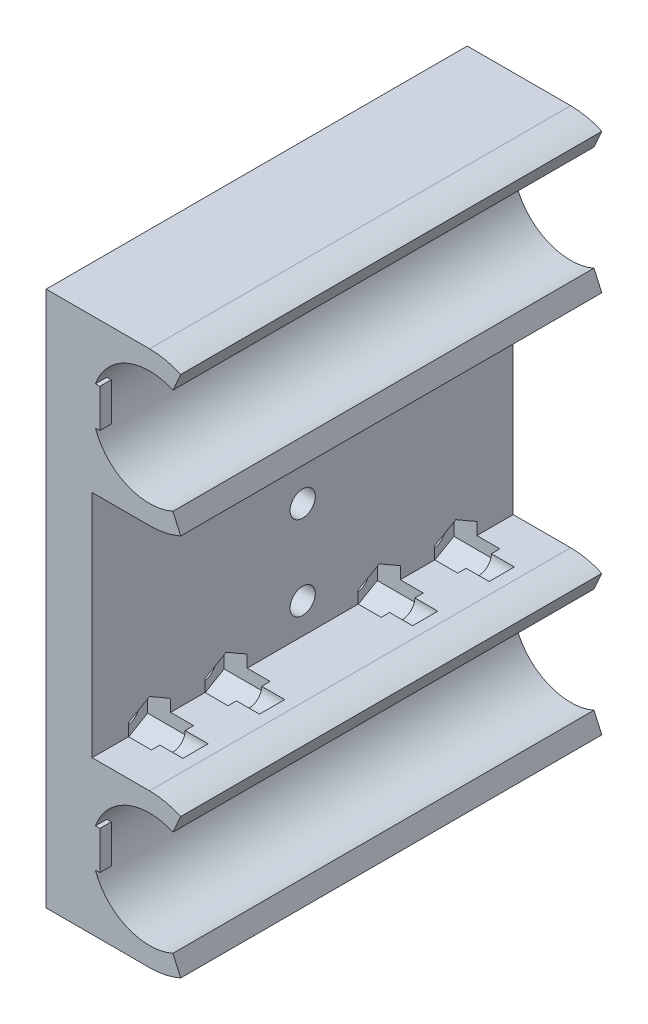
from build123d import *

# Parameters (mm, degrees)
RESSALTO_EXTRUS_O1_DEPTH   = 27.5
CORTE_EXTRUS_O3_DEPTH      = 6
CORTE_EXTRUS_O3_DEPTH_BACK = 10
ESBO_O6_R                  = 1.65
CORTE_EXTRUS_O4_DEPTH      = 3
CORTE_EXTRUS_O4_DEPTH_BACK = 3
CORTE_EXTRUS_O5_DEPTH      = 3
ESBO_O10_W                 = 1.5
ESBO_O10_H                 = 5
RESSALTO_EXTRUS_O3_DEPTH   = 7


with BuildPart() as part:
    # Esboço1 → Ressalto-extrusão1 (new, symmetric)
    with BuildSketch(Plane.XY):
        with BuildLine():
            Line((0, 35), (0, -35))
            Line((0, -35), (13.5, -35))
            ThreePointArc((13.5, -35), (15.581665999, -34.780933834), (17.572127481, -34.133333333))
            Line((17.572127481, -34.133333333), (16.554095611, -31.85))
            ThreePointArc((16.554095611, -31.85), (6, -25), (16.554095611, -18.15))
            Line((16.554095611, -18.15), (17.572127481, -15.866666667))
            ThreePointArc((17.572127481, -15.866666667), (15.581665999, -15.219066166), (13.5, -15))
            Line((13.5, -15), (6, -15))
            Line((6, -15), (6, 15))
            Line((6, 15), (13.5, 15))
            ThreePointArc((13.5, 15), (15.581665999, 15.219066166), (17.572127481, 15.866666667))
            Line((17.572127481, 15.866666667), (16.554095611, 18.15))
            ThreePointArc((16.554095611, 18.15), (6, 25), (16.554095611, 31.85))
            Line((16.554095611, 31.85), (17.572127481, 34.133333333))
            ThreePointArc((17.572127481, 34.133333333), (15.581665999, 34.780933834), (13.5, 35))
            Line((13.5, 35), (0, 35))
        make_face()
    extrude(amount=RESSALTO_EXTRUS_O1_DEPTH, both=True)

    # Esboço6 → Corte-extrusão3 (cut, two sides: drawn at the far end of the back side and taken through both)
    with BuildSketch(Plane(origin=(6, 0, 0), x_dir=(0, 0, -1), z_dir=(1, 0, 0)).offset(-CORTE_EXTRUS_O3_DEPTH_BACK)):
        with Locations((-20, 15)):
            Circle(ESBO_O6_R)
        with Locations((20, -15)):
            Circle(ESBO_O6_R)
        with Locations((10, -15)):
            Circle(ESBO_O6_R)
        with Locations((-10, 15)):
            Circle(ESBO_O6_R)
        with Locations((10, 15)):
            Circle(ESBO_O6_R)
        with Locations((20, 15)):
            Circle(ESBO_O6_R)
        with Locations((-10, -15)):
            Circle(ESBO_O6_R)
        with Locations((-20, -15)):
            Circle(ESBO_O6_R)
        with Locations((0, 11)):
            Circle(ESBO_O6_R)
        Circle(ESBO_O6_R)
        with Locations((0, -11)):
            Circle(ESBO_O6_R)
    extrude(amount=CORTE_EXTRUS_O3_DEPTH + CORTE_EXTRUS_O3_DEPTH_BACK, mode=Mode.SUBTRACT)

    # Esboço8 → Corte-extrusão4 (cut, two sides: drawn at the far end of the back side and taken through both)
    with BuildSketch(Plane(origin=(6, 0, 0), x_dir=(0, 0, -1), z_dir=(1, 0, 0)).offset(-CORTE_EXTRUS_O4_DEPTH_BACK)):
        Polygon((-20, 11.824573519), (-17.25, 13.41228676), (-17.25, 16.58771324), (-20, 18.175426481), (-22.75, 16.58771324), (-22.75, 13.41228676), align=None)
        Polygon((-10, 11.824573519), (-7.25, 13.41228676), (-7.25, 16.58771324), (-10, 18.175426481), (-12.75, 16.58771324), (-12.75, 13.41228676), align=None)
        Polygon((-12.75, -13.41228676), (-10, -11.824573519), (-7.25, -13.41228676), (-7.25, -16.58771324), (-10, -18.175426481), (-12.75, -16.58771324), align=None)
        Polygon((-22.75, -13.41228676), (-20, -11.824573519), (-17.25, -13.41228676), (-17.25, -16.58771324), (-20, -18.175426481), (-22.75, -16.58771324), align=None)
        Polygon((20, -11.824573519), (17.25, -13.41228676), (17.25, -16.58771324), (20, -18.175426481), (22.75, -16.58771324), (22.75, -13.41228676), align=None)
        Polygon((10, -11.824573519), (7.25, -13.41228676), (7.25, -16.58771324), (10, -18.175426481), (12.75, -16.58771324), (12.75, -13.41228676), align=None)
        Polygon((12.75, 13.41228676), (10, 11.824573519), (7.25, 13.41228676), (7.25, 16.58771324), (10, 18.175426481), (12.75, 16.58771324), align=None)
        Polygon((22.75, 13.41228676), (20, 11.824573519), (17.25, 13.41228676), (17.25, 16.58771324), (20, 18.175426481), (22.75, 16.58771324), align=None)
    extrude(amount=CORTE_EXTRUS_O4_DEPTH + CORTE_EXTRUS_O4_DEPTH_BACK, mode=Mode.SUBTRACT)

    # Esboço9 → Corte-extrusão5 (cut)
    with BuildSketch(Plane.ZY):
        Polygon((3.175426481, 11), (1.58771324, 13.75), (-1.58771324, 13.75), (-3.175426481, 11), (-1.58771324, 8.25), (1.58771324, 8.25), align=None)
        Polygon((3.175426481, 0), (1.58771324, 2.75), (-1.58771324, 2.75), (-3.175426481, 0), (-1.58771324, -2.75), (1.58771324, -2.75), align=None)
        Polygon((3.175426481, -11), (1.58771324, -8.25), (-1.58771324, -8.25), (-3.175426481, -11), (-1.58771324, -13.75), (1.58771324, -13.75), align=None)
    extrude(amount=-CORTE_EXTRUS_O5_DEPTH, mode=Mode.SUBTRACT)

    # Esboço10 → Ressalto-extrusão3 (add)
    with BuildSketch(Plane.ZY):
        with Locations((-26.75, 25)):
            Rectangle(ESBO_O10_W, ESBO_O10_H)
        with Locations((26.75, 25)):
            Rectangle(ESBO_O10_W, ESBO_O10_H)
        with Locations((26.75, -25)):
            Rectangle(ESBO_O10_W, ESBO_O10_H)
        with Locations((-26.75, -25)):
            Rectangle(ESBO_O10_W, ESBO_O10_H)
    extrude(amount=-RESSALTO_EXTRUS_O3_DEPTH)


solid = part.part
